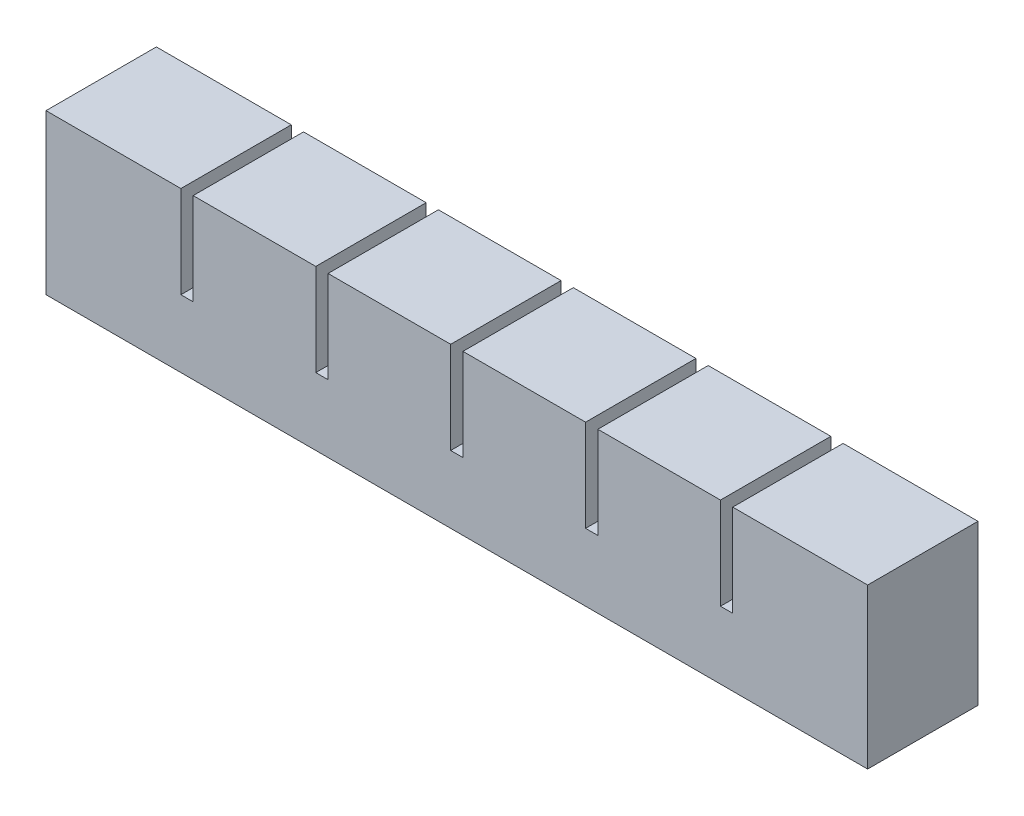
from build123d import *

# Parameters (mm, degrees)
SKETCH1_W           = 20
SKETCH1_H           = 20
BOSS_EXTRUDE1_DEPTH = 18
SKETCH2_W           = 8
SKETCH2_H           = 6
CUT_EXTRUDE1_DEPTH  = 14
SKETCH3_W           = 18
SKETCH3_H           = 5
BOSS_EXTRUDE2_DEPTH = 2
LPATTERN1_COUNT     = 6
LPATTERN1_PITCH     = 22
SKETCH4_W           = 18
SKETCH4_H           = 15
BOSS_EXTRUDE3_DEPTH = 2
SKETCH5_W           = 18
SKETCH5_H           = 20
BOSS_EXTRUDE4_DEPTH = 2
SKETCH6_W           = 118
SKETCH6_H           = 2
CUT_EXTRUDE2_DEPTH  = 2
SKETCH7_W           = 134
SKETCH7_H           = 18
BOSS_EXTRUDE5_DEPTH = 6


with BuildPart() as part:
    # Sketch1 → Boss-Extrude1 (new body)
    with BuildSketch(Plane.XY):
        with Locations((10, 10)):
            Rectangle(SKETCH1_W, SKETCH1_H)
    extrude(amount=BOSS_EXTRUDE1_DEPTH)

    # Sketch2 → Cut-Extrude1 (cut)
    with BuildSketch(Plane(origin=(0, 0, 0), x_dir=(-1, 0, 0), z_dir=(0, -1, 0))):
        with Locations((-10, -9)):
            Rectangle(SKETCH2_W, SKETCH2_H)
    extrude(amount=-CUT_EXTRUDE1_DEPTH, mode=Mode.SUBTRACT)

    # Sketch3 → Boss-Extrude2 (add)
    with BuildSketch(Plane(origin=(20, 0, 0), x_dir=(0, 0, -1), z_dir=(1, 0, 0))):
        with Locations((-9, 2.5)):
            Rectangle(SKETCH3_W, SKETCH3_H)
    extrude(amount=BOSS_EXTRUDE2_DEPTH)


with BuildPart() as lpattern1_1:
    # LPattern1: pattern copy
    add(part.part.moved(Location(Vector(1, 0, 0) * (1 * LPATTERN1_PITCH))))


with BuildPart() as lpattern1_2:
    # LPattern1: pattern copy
    add(part.part.moved(Location(Vector(1, 0, 0) * (2 * LPATTERN1_PITCH))))


with BuildPart() as lpattern1_3:
    # LPattern1: pattern copy
    add(part.part.moved(Location(Vector(1, 0, 0) * (3 * LPATTERN1_PITCH))))


with BuildPart() as lpattern1_4:
    # LPattern1: pattern copy
    add(part.part.moved(Location(Vector(1, 0, 0) * (4 * LPATTERN1_PITCH))))


with BuildPart() as lpattern1_5:
    # LPattern1: pattern copy
    add(part.part.moved(Location(Vector(1, 0, 0) * (5 * LPATTERN1_PITCH))))

    # Sketch4 → Boss-Extrude3 (add)
    with BuildSketch(Plane(origin=(130, 0, 0), x_dir=(0, 0, -1), z_dir=(1, 0, 0))):
        with Locations((-9, 12.5)):
            Rectangle(SKETCH4_W, SKETCH4_H)
    extrude(amount=BOSS_EXTRUDE3_DEPTH)


with BuildPart() as part_1:
    add(part.part)

    # Sketch5 → Boss-Extrude4 (add)
    with BuildSketch(Plane.ZY):
        with Locations((9, 10)):
            Rectangle(SKETCH5_W, SKETCH5_H)
    extrude(amount=BOSS_EXTRUDE4_DEPTH)


with BuildPart() as lpattern1_4_1:
    add(lpattern1_4.part)

    # Combine1: union LPattern1_5, part, LPattern1_1, LPattern1_2, LPattern1_3
    add(lpattern1_5.part)
    add(part_1.part)
    add(lpattern1_1.part)
    add(lpattern1_2.part)
    add(lpattern1_3.part)

    # Sketch6 → Cut-Extrude2 (cut)
    with BuildSketch(Plane(origin=(0, 0, 0), x_dir=(-1, 0, 0), z_dir=(0, -1, 0))):
        with Locations((-65, -9)):
            Rectangle(SKETCH6_W, SKETCH6_H)
    extrude(amount=-CUT_EXTRUDE2_DEPTH, mode=Mode.SUBTRACT)

    # Sketch7 → Boss-Extrude5 (add)
    with BuildSketch(Plane(origin=(0, 0, 0), x_dir=(-1, 0, 0), z_dir=(0, -1, 0))):
        with Locations((-65, -9)):
            Rectangle(SKETCH7_W, SKETCH7_H)
    extrude(amount=BOSS_EXTRUDE5_DEPTH)


solid = lpattern1_4_1.part
